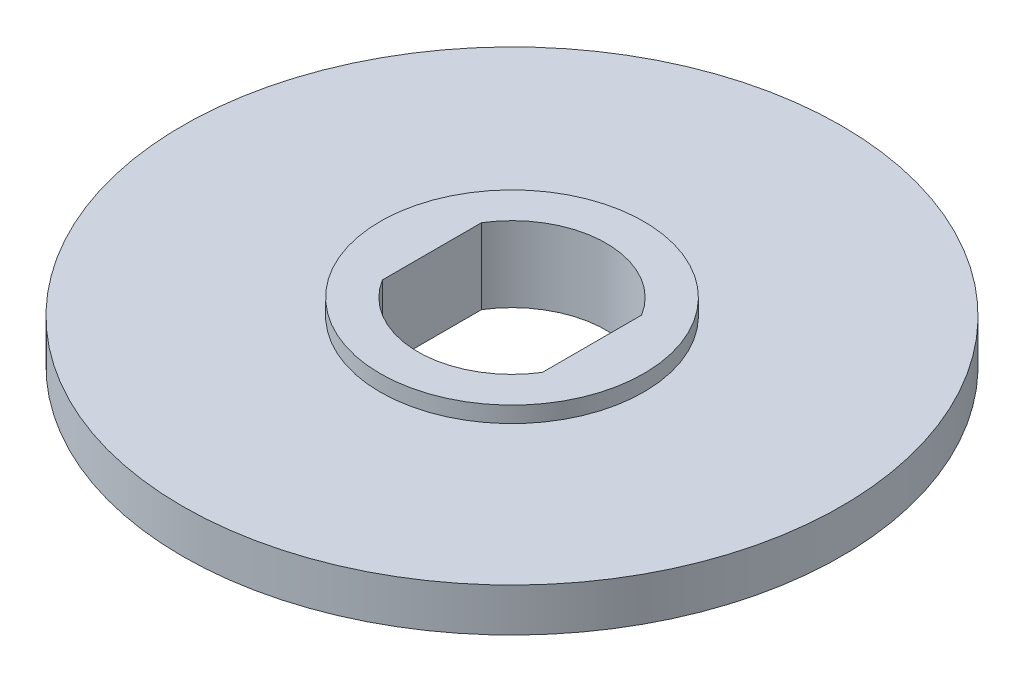
from build123d import *

# Parameters (mm, degrees)
SKETCH1_R           = 7
BOSS_EXTRUDE1_DEPTH = 2
SKETCH1_3_R         = 17.5
SKETCH1_3_R_2       = 7
BOSS_EXTRUDE2_DEPTH = 1.15


with BuildPart() as part:
    # Sketch1 → Boss-Extrude1 (new, symmetric)
    with BuildSketch(Plane(origin=(0, 0, 0), x_dir=(1, 0, 0), z_dir=(0, 1, 0))):
        Circle(SKETCH1_R)
        with BuildLine():
            Line((-4.25, -2.633913438), (-4.25, 2.633913438))
            ThreePointArc((-4.25, 2.633913438), (0, 5), (4.25, 2.633913438))
            Line((4.25, 2.633913438), (4.25, -2.633913438))
            ThreePointArc((4.25, -2.633913438), (0, -5), (-4.25, -2.633913438))
        make_face(mode=Mode.SUBTRACT)
    extrude(amount=BOSS_EXTRUDE1_DEPTH, both=True)

    # Sketch1_3 → Boss-Extrude2 (add, symmetric)
    with BuildSketch(Plane(origin=(0, 0, 0), x_dir=(1, 0, 0), z_dir=(0, 1, 0))):
        Circle(SKETCH1_3_R)
        Circle(SKETCH1_3_R_2, mode=Mode.SUBTRACT)
    extrude(amount=BOSS_EXTRUDE2_DEPTH, both=True)


solid = part.part
